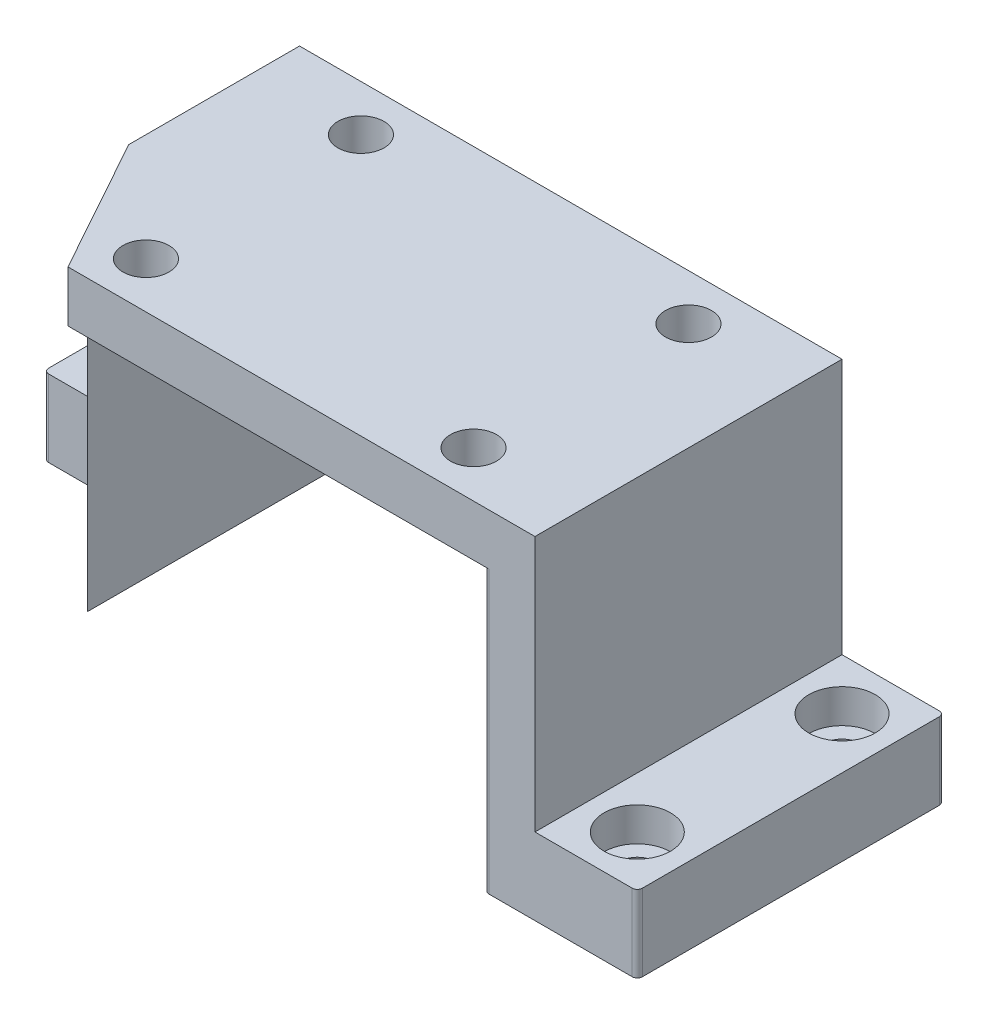
from build123d import *

# Parameters (mm, degrees)
SKETCH1_W           = 106
SKETCH1_H           = 60
BOSS_EXTRUDE1_DEPTH = 10
SKETCH2_W           = 10
SKETCH2_H           = 60
BOSS_EXTRUDE2_DEPTH = 55
SKETCH3_W           = 60
SKETCH3_H           = 15
BOSS_EXTRUDE3_DEPTH = 20
SKETCH4_W           = 30
SKETCH4_H           = 15
BOSS_EXTRUDE4_DEPTH = 20
SKETCH5_R           = 4.5
CUT_EXTRUDE1_DEPTH  = 66
SKETCH6_R           = 6.5
CUT_EXTRUDE2_DEPTH  = 6.6
SKETCH7_R           = 3.3
CUT_EXTRUDE3_DEPTH  = 9.4
CUT_EXTRUDE4_DEPTH  = 66
FILLET1_R           = 1


with BuildPart() as part:
    # Sketch1 → Boss-Extrude1 (new body)
    with BuildSketch(Plane(origin=(0, 0, 0), x_dir=(1, 0, 0), z_dir=(0, 1, 0))):
        Rectangle(SKETCH1_W, SKETCH1_H)
    extrude(amount=BOSS_EXTRUDE1_DEPTH)

    # Sketch2 → Boss-Extrude2 (add)
    with BuildSketch(Plane.XZ):
        with Locations((-48, 0)):
            Rectangle(SKETCH2_W, SKETCH2_H)
        with Locations((48, 0)):
            Rectangle(SKETCH2_W, SKETCH2_H)
    extrude(amount=BOSS_EXTRUDE2_DEPTH)

    # Sketch3 → Boss-Extrude3 (add)
    with BuildSketch(Plane(origin=(53, 0, 0), x_dir=(0, 0, -1), z_dir=(1, 0, 0))):
        with Locations((0, -47.5)):
            Rectangle(SKETCH3_W, SKETCH3_H)
    extrude(amount=BOSS_EXTRUDE3_DEPTH)

    # Sketch4 → Boss-Extrude4 (add)
    with BuildSketch(Plane.ZY.offset(53)):
        with Locations((-15, -47.5)):
            Rectangle(SKETCH4_W, SKETCH4_H)
    extrude(amount=BOSS_EXTRUDE4_DEPTH)

    # Sketch5 → Cut-Extrude1 (cut, through all)
    with BuildSketch(Plane(origin=(0, 10, 0), x_dir=(1, 0, 0), z_dir=(0, 1, 0))):
        with Locations((-32, 21)):
            Circle(SKETCH5_R)
        with Locations((32, 21)):
            Circle(SKETCH5_R)
        with Locations((32, -21)):
            Circle(SKETCH5_R)
        with Locations((-32, -21)):
            Circle(SKETCH5_R)
    extrude(amount=-CUT_EXTRUDE1_DEPTH, mode=Mode.SUBTRACT)

    # Sketch6 → Cut-Extrude2 (cut)
    with BuildSketch(Plane(origin=(0, -40, 0), x_dir=(1, 0, 0), z_dir=(0, 1, 0))):
        with Locations((63, 20)):
            Circle(SKETCH6_R)
        with Locations((63, -20)):
            Circle(SKETCH6_R)
        with Locations((-63, 20)):
            Circle(SKETCH6_R)
    extrude(amount=-CUT_EXTRUDE2_DEPTH, mode=Mode.SUBTRACT)

    # Sketch7 → Cut-Extrude3 (cut, through all)
    with BuildSketch(Plane(origin=(0, -46.6, 0), x_dir=(1, 0, 0), z_dir=(0, 1, 0))):
        with Locations((-63, 20)):
            Circle(SKETCH7_R)
        with Locations((63, -20)):
            Circle(SKETCH7_R)
        with Locations((63, 20)):
            Circle(SKETCH7_R)
    extrude(amount=-CUT_EXTRUDE3_DEPTH, mode=Mode.SUBTRACT)

    # Sketch8 → Cut-Extrude4 (cut, through all)
    with BuildSketch(Plane(origin=(0, 10, 0), x_dir=(1, 0, 0), z_dir=(0, 1, 0))):
        Polygon((-38.239, -30), (-53, -3.370451084), (-53, -30), align=None)
    extrude(amount=-CUT_EXTRUDE4_DEPTH, mode=Mode.SUBTRACT)

    # Fillet1
    fillet1_edges = [part.edges().sort_by_distance(p)[0] for p in [
        (-43, -27.5, -30),
        (43, -27.5, 30),
        (43, -27.5, -30),
        (73, -47.5, 30),
        (73, -47.5, -30),
        (-73, -47.5, -30),
        (-73, -47.5, 0),
    ]]
    fillet(fillet1_edges, radius=FILLET1_R)


solid = part.part
